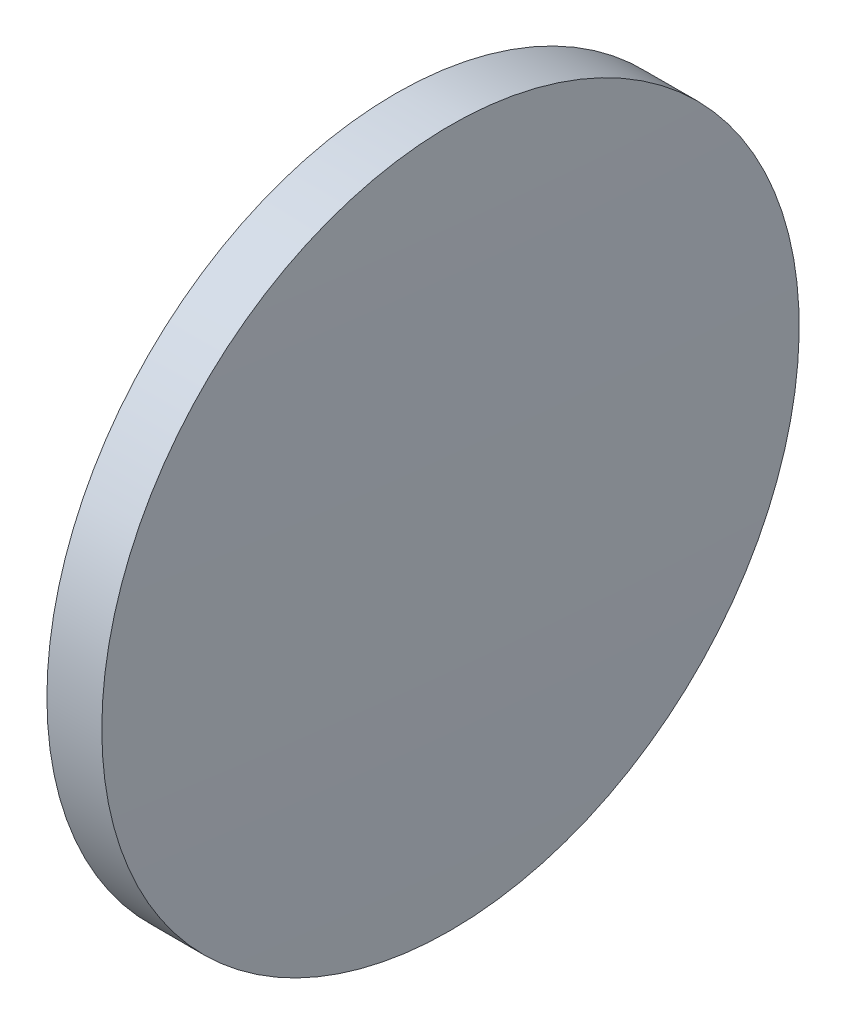
from build123d import *

# Parameters (mm, degrees)
SKETCH_1_ONE_SIDE_W = 1.999342857
SKETCH_1_ONE_SIDE_H = 12.7


with BuildPart() as part:
    # 草图1 one side → 旋转1 (revolve)
    with BuildSketch(Plane.XY, mode=Mode.PRIVATE) as revolve_1_sk:
        with Locations((86.458193775, 54.966113023)):
            Rectangle(SKETCH_1_ONE_SIDE_W, SKETCH_1_ONE_SIDE_H)
        with BuildLine():
            Line((85.308226918, 48.616113023), (85.458522346, 48.616113023))
            Line((85.458522346, 48.616113023), (85.458522346, 61.316113023))
            ThreePointArc((85.458522346, 61.316113023), (85.34580209, 54.966557667), (85.308226918, 48.616113023))
        make_face()
        with BuildLine():
            Line((87.457865203, 48.616113023), (87.608160632, 48.616113023))
            ThreePointArc((87.608160632, 48.616113023), (87.570585459, 54.966557667), (87.457865203, 61.316113023))
            Line((87.457865203, 61.316113023), (87.457865203, 48.616113023))
        make_face()
    revolve(revolve_1_sk.sketch.rotate(Axis((79.305401351, 48.616113023, 0), (1, 0, 0)), 90), axis=Axis((79.305401351, 48.616113023, 0), (1, 0, 0)))  # turned: the seam where the file's is


solid = part.part
